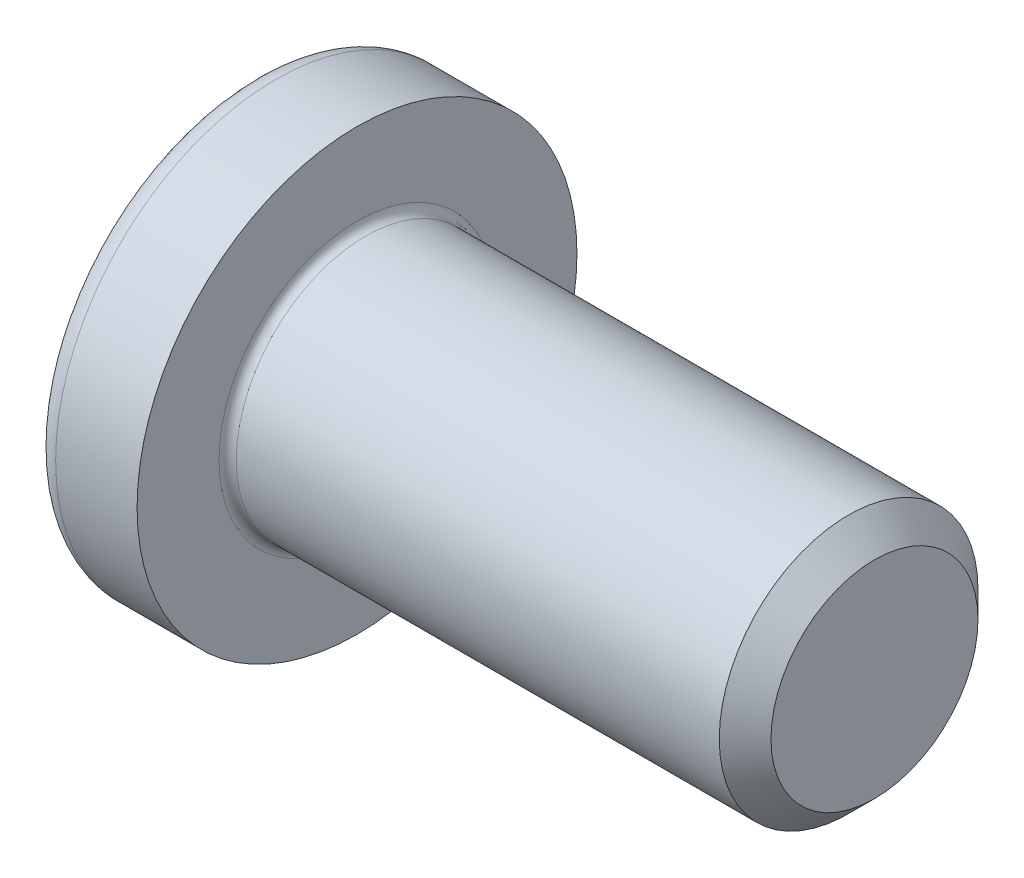
from build123d import *

# Parameters (mm, degrees)
FILLET1_R       = 0.1
SKETCH3_W       = 0.9
SKETCH3_H       = 3.5
SKETCH4_W       = 0.9
SKETCH4_H       = 1.754964664
RECPAT_COUNT    = 2
RECPAT_ANGLE    = 90
CHANFREIN1_SIZE = 0.3


with BuildPart() as part:
    # BodySke → Base-Revolve (revolve)
    with BuildSketch(Plane.XY):
        with BuildLine():
            Line((1.8, 1.5), (1.8, 2.55))
            Line((1.8, 2.55), (0.855787168, 2.55))
            ThreePointArc((0.855787168, 2.55), (0.718382578, 2.512421984), (0.619225336, 2.410147992))
            ThreePointArc((0.619225336, 2.410147992), (0.157280035, 1.244211935), (0, 0))
            Line((0, 0), (7.8, 0))
            Line((7.8, 0), (7.8, 1.5))
            Line((7.8, 1.5), (1.8, 1.5))
        make_face()
    revolve(axis=Axis((-25.4, 0, 0), (1, 0, 0)))

    # Fillet1
    fillet1_edges = [part.edges().sort_by_distance(p)[0] for p in [
        (1.8, -1.5, 0),
    ]]
    fillet(fillet1_edges, radius=FILLET1_R)

    # Sketch3 → Recess section 0
    with BuildSketch(Plane(origin=(0, 0, 0), x_dir=(0, 0, -1), z_dir=(1, 0, 0))):
        Rectangle(SKETCH3_W, SKETCH3_H)
    # Sketch4 → Recess section 1
    with BuildSketch(Plane(origin=(1.75, 0, 0), x_dir=(0, 0, -1), z_dir=(1, 0, 0))):
        Rectangle(SKETCH4_W, SKETCH4_H)
    recess = loft(mode=Mode.SUBTRACT)

    # RecPat: Recess ×2 about axis
    recpat_axis = Axis((0, 0, 0), (1, 0, 0))
    for i in range(1, RECPAT_COUNT):
        add(recess.rotate(recpat_axis, i * RECPAT_ANGLE / (RECPAT_COUNT - 1)), mode=Mode.SUBTRACT)

    # RecCorSke → RecessCore (revolve, cut)
    with BuildSketch(Plane.XY):
        Polygon((0, 0), (0, 0.678371921), (1.75, 0.556), (1.930655351, 0), align=None)
    revolve(axis=Axis((-3.175, 0, 0), (1, 0, 0)), mode=Mode.SUBTRACT)

    # Chanfrein1
    chanfrein1_edges = [part.edges().sort_by_distance(p)[0] for p in [
        (7.8, -1.5, 0),
    ]]
    chamfer(chanfrein1_edges, length=CHANFREIN1_SIZE)


solid = part.part
